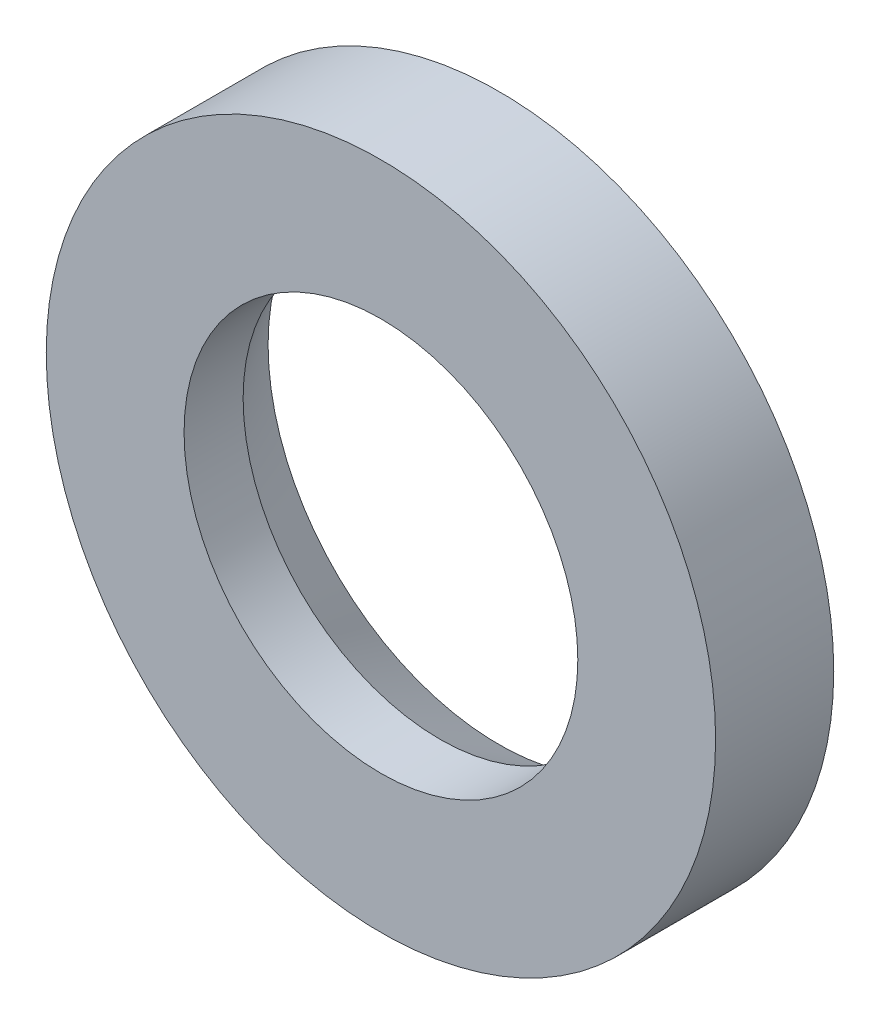
from build123d import *

# Parameters (mm, degrees)
SKETCH1_R           = 1.7
BOSS_EXTRUDE1_DEPTH = 0.6
SKETCH2_R           = 1
CUT_EXTRUDE1_DEPTH  = 1.6
CHAMFER1_SIZE       = 0.3
CHAMFER1_SIZE2      = 0.173205081


with BuildPart() as part:
    # Sketch1 → Boss-Extrude1 (new body)
    with BuildSketch(Plane.XY):
        Circle(SKETCH1_R)
    extrude(amount=-BOSS_EXTRUDE1_DEPTH)

    # Sketch2 → Cut-Extrude1 (cut, through all)
    with BuildSketch(Plane.XY):
        Circle(SKETCH2_R)
    extrude(amount=-CUT_EXTRUDE1_DEPTH, mode=Mode.SUBTRACT)

    # Chamfer1
    chamfer1_edges = [part.edges().sort_by_distance(p)[0] for p in [
        (-1, 0, -0.6),
    ]]
    chamfer1_side = [part.faces().sort_by_distance(p)[0] for p in [
        (-1, 0, -0.3),
    ]]
    chamfer(chamfer1_edges, length=CHAMFER1_SIZE, length2=CHAMFER1_SIZE2, reference=chamfer1_side[0])


solid = part.part
